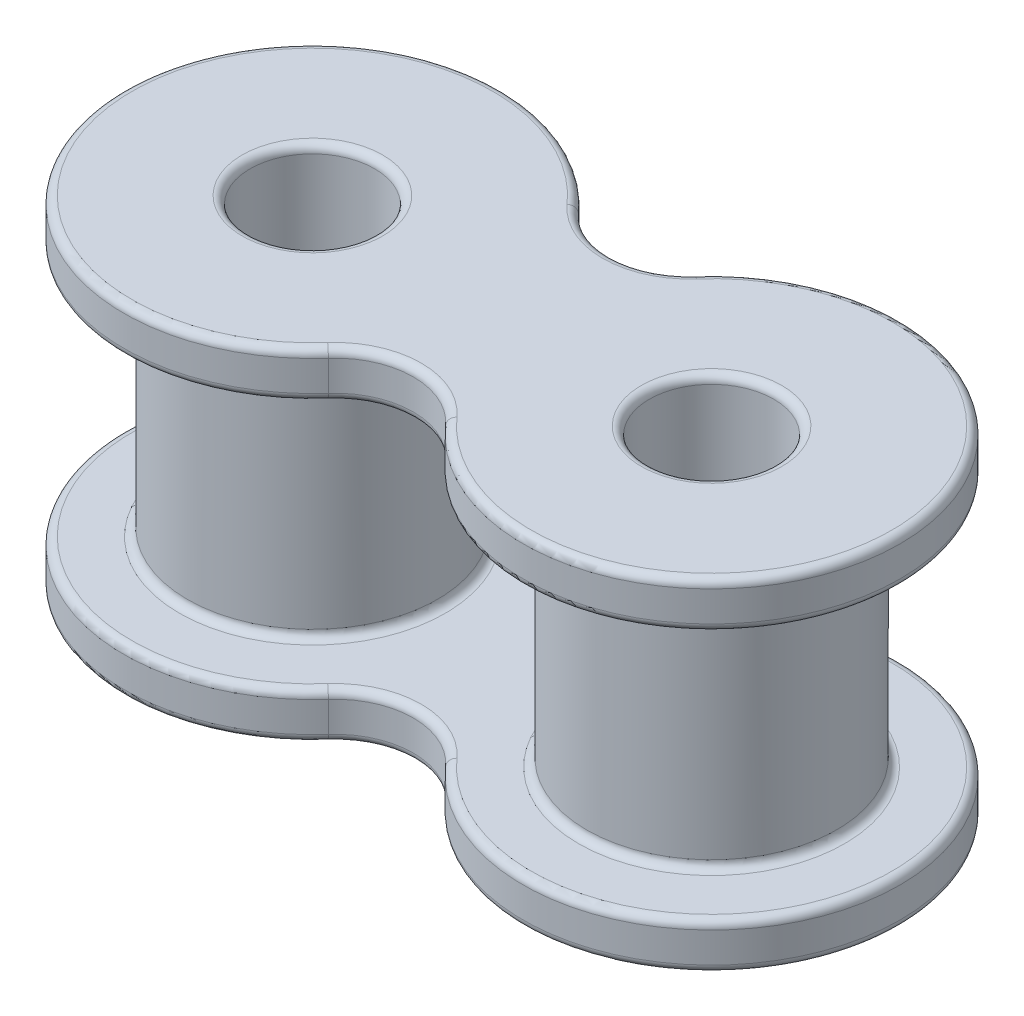
from build123d import *

# Parameters (mm, degrees)
SKETCH1_R             = 1.9812
BOSS_EXTRUDE1_DEPTH   = 0.7366
SKETCH5_R             = 3.9751
SKETCH5_R_2           = 1.9812
BOSS_EXTRUDE2_DEPTH   = 7.9248
FILLET_2_R            = 0.254
FILLET_2_OF_MIRROR2_R = 0.254


with BuildPart() as part:
    # Sketch1 → Boss-Extrude1 (new body, symmetric)
    with BuildSketch(Plane(origin=(0, 0, 0), x_dir=(1, 0, 0), z_dir=(0, 1, 0))):
        with BuildLine():
            ThreePointArc((-1.865444619, 3.977636785), (-12.3444, 0), (-1.865444619, -3.977636785))
            ThreePointArc((-1.865444619, -3.977636785), (0, -3.138721939), (1.865444619, -3.977636785))
            ThreePointArc((1.865444619, -3.977636785), (12.3444, 0), (1.865444619, 3.977636785))
            ThreePointArc((1.865444619, 3.977636785), (0, 3.138721939), (-1.865444619, 3.977636785))
        make_face()
        with Locations((-6.35, 0)):
            Circle(SKETCH1_R, mode=Mode.SUBTRACT)
        with Locations((6.35, 0)):
            Circle(SKETCH1_R, mode=Mode.SUBTRACT)
    boss_extrude1 = extrude(amount=BOSS_EXTRUDE1_DEPTH, both=True)

    # Sketch5 → Boss-Extrude2 (add)
    with BuildSketch(Plane(origin=(0, 0.7366, 0), x_dir=(1, 0, 0), z_dir=(0, 1, 0))):
        with Locations((6.35, 0)):
            Circle(SKETCH5_R)
        with Locations((6.35, 0)):
            Circle(SKETCH5_R_2, mode=Mode.SUBTRACT)
        with Locations((-6.35, 0)):
            Circle(SKETCH5_R)
        with Locations((-6.35, 0)):
            Circle(SKETCH5_R_2, mode=Mode.SUBTRACT)
    extrude(amount=BOSS_EXTRUDE2_DEPTH)

    # Fillet 2
    fillet_2_edges = [part.edges().sort_by_distance(p)[0] for p in [
        (-8.3312, -0.7366, 0),
        (0, 0.7366, 3.138721939),
        (4.3688, -0.7366, 0),
        (12.3444, 0.7366, 0),
        (2.3749, 0.7366, 0),
        (-10.3251, 0.7366, 0),
        (0, 0.7366, -3.138721939),
        (12.3444, -0.7366, 0),
        (0, -0.7366, 3.138721939),
        (-12.3444, -0.7366, 0),
        (0, -0.7366, -3.138721939),
        (-12.3444, 0.7366, 0),
    ]]
    fillet(fillet_2_edges, radius=FILLET_2_R)

    # Mirror2: Boss-Extrude1 across plane
    add(boss_extrude1.mirror(Plane.ZX.offset(4.699)))

    # Fillet 2 of Mirror2
    fillet_2_of_mirror2_edges = [part.edges().sort_by_distance(p)[0] for p in [
        (-8.3312, 10.1346, 0),
        (0, 8.6614, 3.138721939),
        (4.3688, 10.1346, 0),
        (12.3444, 8.6614, 0),
        (2.3749, 8.6614, 0),
        (-10.3251, 8.6614, 0),
        (0, 8.6614, -3.138721939),
        (12.3444, 10.1346, 0),
        (0, 10.1346, 3.138721939),
        (-12.3444, 10.1346, 0),
        (0, 10.1346, -3.138721939),
        (-12.3444, 8.6614, 0),
    ]]
    fillet(fillet_2_of_mirror2_edges, radius=FILLET_2_OF_MIRROR2_R)


solid = part.part
